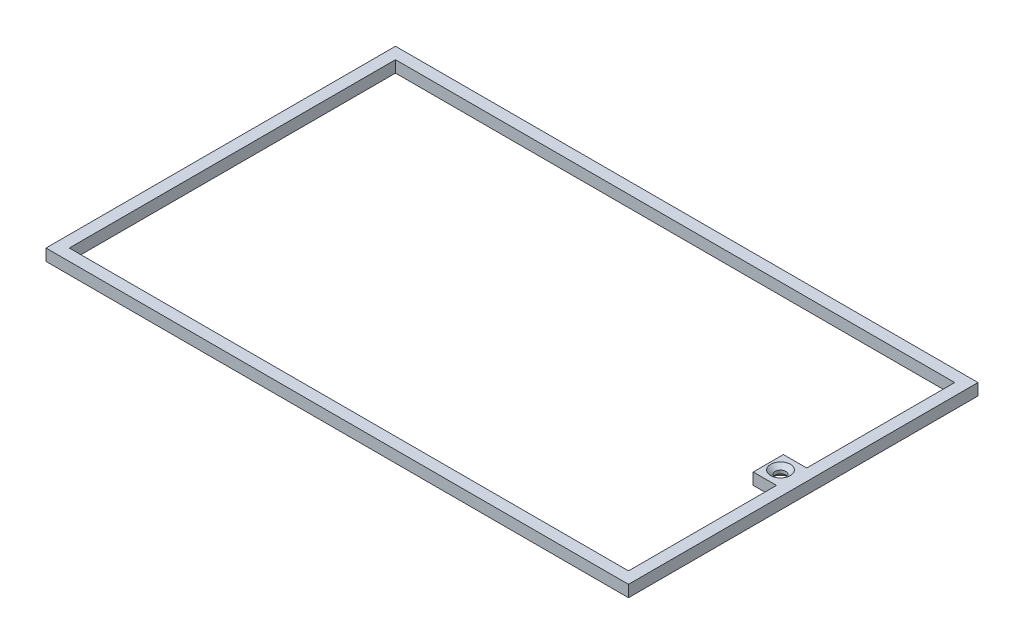
from build123d import *

# Parameters (mm, degrees)
SKETCH1_W                                         = 250
SKETCH1_H                                         = 150
BOSS_EXTRUDE1_DEPTH                               = 5
CUT_EXTRUDE1_DEPTH                                = 5
CSK_FOR_8_FLAT_HEAD_MACHINE_SCREW_100_D           = 4.4958
CSK_FOR_8_FLAT_HEAD_MACHINE_SCREW_100_CSINK_D     = 8.4328
CSK_FOR_8_FLAT_HEAD_MACHINE_SCREW_100_CSINK_ANGLE = 100
CHAMFER1_SIZE                                     = 2


with BuildPart() as part:
    # Sketch1 → Boss-Extrude1 (new body)
    with BuildSketch(Plane(origin=(0, 0, 0), x_dir=(1, 0, 0), z_dir=(0, 1, 0))):
        with Locations((125, 75)):
            Rectangle(SKETCH1_W, SKETCH1_H)
    extrude(amount=BOSS_EXTRUDE1_DEPTH)

    # Sketch2 → Cut-Extrude1 (cut)
    with BuildSketch(Plane(origin=(0, 5, 0), x_dir=(1, 0, 0), z_dir=(0, 1, 0))):
        Polygon((5, 5), (245, 5), (245, 68.522708921), (235, 68.522708921), (235, 81.477291079), (245, 81.477291079), (245, 145), (5, 145), align=None)
    extrude(amount=-CUT_EXTRUDE1_DEPTH, mode=Mode.SUBTRACT)

    # CSK for #8 Flat Head Machine Screw (100)1 (through all)
    with Locations(Plane(origin=(240.110859841, 5, -75.135992341), x_dir=(0, 0, 1), z_dir=(0, 1, 0))):
        with Locations((0, 0)):
            CounterSinkHole(CSK_FOR_8_FLAT_HEAD_MACHINE_SCREW_100_D / 2, CSK_FOR_8_FLAT_HEAD_MACHINE_SCREW_100_CSINK_D / 2, counter_sink_angle=CSK_FOR_8_FLAT_HEAD_MACHINE_SCREW_100_CSINK_ANGLE)

    # Chamfer1
    chamfer1_edges = [part.edges().sort_by_distance(p)[0] for p in [
        (240.110859841, 0, -72.888092341),
    ]]
    chamfer(chamfer1_edges, length=CHAMFER1_SIZE)


solid = part.part
